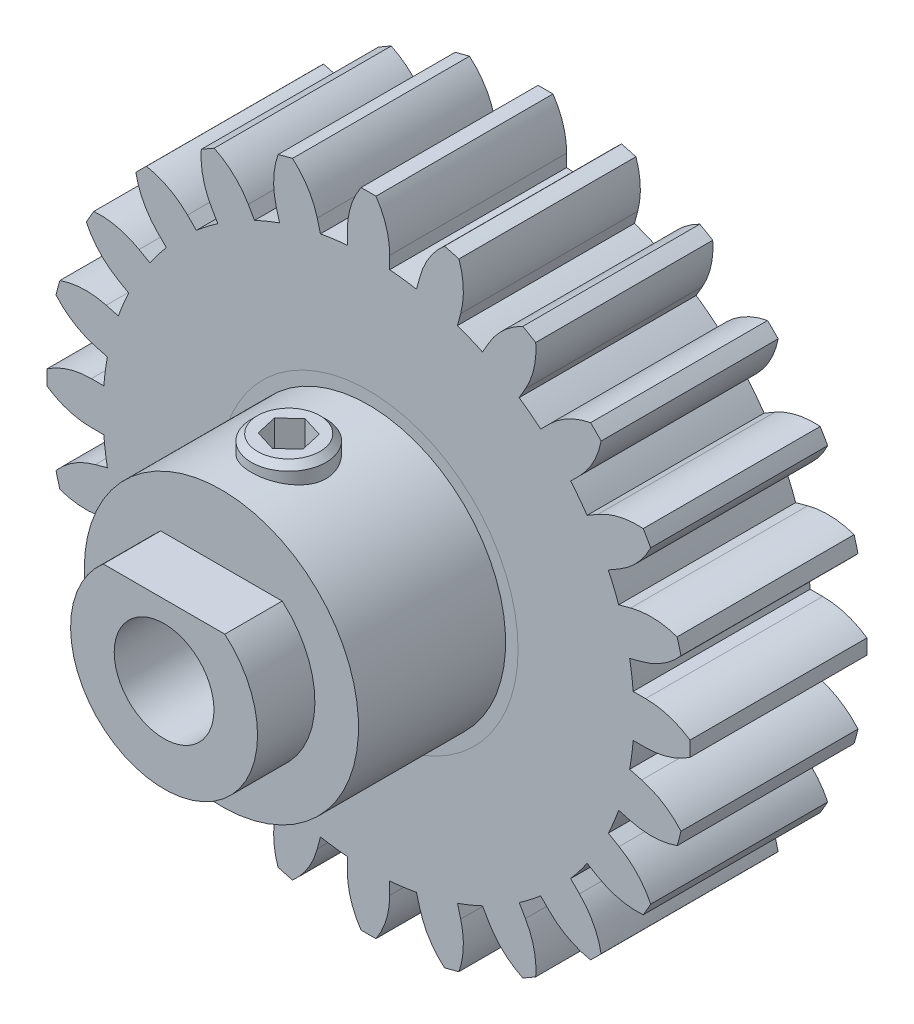
from build123d import *

# Parameters (mm, degrees)
SKETCH5_R           = 1.25
CUT_EXTRUDE1_DEPTH  = 7
SKETCH6_W           = 4.874423042
SKETCH6_H           = 1.8
CUT_EXTRUDE2_DEPTH  = 3.3000001
SKETCH1_R           = 10.65
SKETCH1_R_2         = 6
BOSS_EXTRUDE1_DEPTH = 7.1
BOSS_EXTRUDE2_DEPTH = 7.1
CIRPATTERN1_COUNT   = 24
SKETCH7_R           = 1.5
BOSS_EXTRUDE3_DEPTH = 4.6
CHAMFER1_SIZE       = 0.25
CUT_EXTRUDE3_DEPTH  = 2


with BuildPart() as part:
    # Sketch4 → Revolve1 (revolve)
    with BuildSketch(Plane(origin=(0, 0, 0), x_dir=(1, 0, 0), z_dir=(0, 1, 0))):
        Polygon((2, 0.5), (2, -15.3), (3.75, -15.3), (3.75, -13), (5.5, -13), (5.5, -7.1), (6, -7.1), (6, 0), (5.5, 0), (5.5, 0.5), align=None)
    revolve(axis=Axis((0, 0, -23.226019237), (0, 0, 1)))

    # Sketch5 → Cut-Extrude1 (cut, through all)
    with BuildSketch(Plane(origin=(0, 0, 0), x_dir=(1, 0, 0), z_dir=(0, 1, 0))):
        with Locations((0, -10.3)):
            Circle(SKETCH5_R)
    extrude(amount=CUT_EXTRUDE1_DEPTH, mode=Mode.SUBTRACT)

    # Sketch6 → Cut-Extrude2 (cut, through all)
    with BuildSketch(Plane.XY.offset(13)):
        with Locations((0, 3.75)):
            Rectangle(SKETCH6_W, SKETCH6_H)
    extrude(amount=CUT_EXTRUDE2_DEPTH, mode=Mode.SUBTRACT)


with BuildPart() as body_2:
    # Sketch1 → Boss-Extrude1 (new body)
    with BuildSketch(Plane.XY):
        Circle(SKETCH1_R)
        Circle(SKETCH1_R_2, mode=Mode.SUBTRACT)
    extrude(amount=BOSS_EXTRUDE1_DEPTH)

    # Sketch2 → Boss-Extrude2 (add)
    with BuildSketch(Plane.XY):
        with BuildLine():
            Line((0.85, 10.616025622), (0.85, 11.116025622))
            ThreePointArc((0.85, 11.116025622), (0.709367616, 12.047775151), (0.3, 12.896511156))
            ThreePointArc((0.3, 12.896511156), (0, 12.9), (-0.3, 12.896511156))
            ThreePointArc((-0.3, 12.896511156), (-0.709367616, 12.047775151), (-0.85, 11.116025622))
            Line((-0.85, 11.116025622), (-0.85, 10.616025622))
            Line((-0.85, 10.616025622), (0.85, 10.616025622))
        make_face()
    boss_extrude2 = extrude(amount=BOSS_EXTRUDE2_DEPTH)

    # CirPattern1: Boss-Extrude2 ×24 about axis
    cirpattern1_axis = Axis((0, 0, 0), (0, 0, 1))
    for i in range(1, CIRPATTERN1_COUNT):
        add(boss_extrude2.rotate(cirpattern1_axis, i * 360 / CIRPATTERN1_COUNT))


with BuildPart() as body_3:
    # Sketch7 → Boss-Extrude3 (new body)
    with BuildSketch(Plane(origin=(0, 1.5, 0), x_dir=(1, 0, 0), z_dir=(0, 1, 0))):
        with Locations((0, -10.3)):
            Circle(SKETCH7_R)
    extrude(amount=BOSS_EXTRUDE3_DEPTH)

    # Chamfer1
    chamfer1_edges = [body_3.edges().sort_by_distance(p)[0] for p in [
        (-1.5, 6.1, 10.3),
    ]]
    chamfer(chamfer1_edges, length=CHAMFER1_SIZE)

    # Sketch8 → Cut-Extrude3 (cut)
    with BuildSketch(Plane(origin=(0, 6.1, 0), x_dir=(1, 0, 0), z_dir=(0, 1, 0))):
        Polygon((0.190579177, -11.144795583), (0.826904025, -10.557351382), (0.636324847, -9.712555799), (-0.190579177, -9.455204417), (-0.826904025, -10.042648618), (-0.636324847, -10.887444201), align=None)
    extrude(amount=-CUT_EXTRUDE3_DEPTH, mode=Mode.SUBTRACT)


solid = Compound([part.part, body_2.part, body_3.part])
